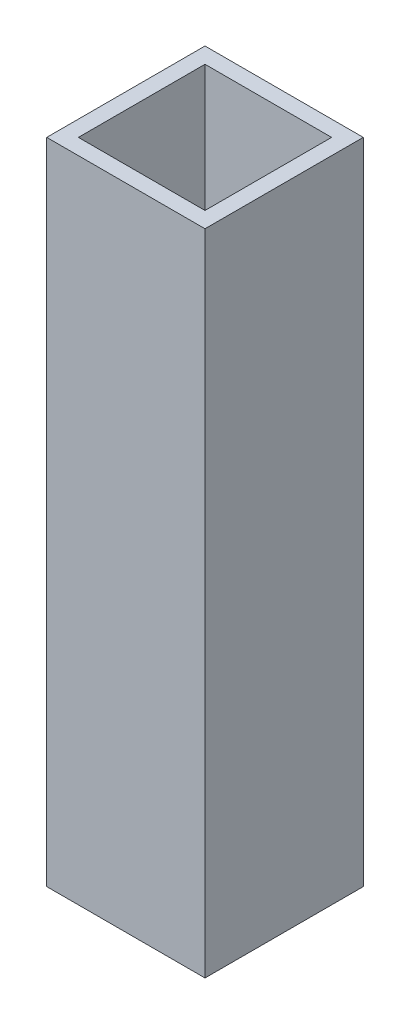
from build123d import *

# Parameters (mm, degrees)
SKETCH2_W           = 50
SKETCH2_H           = 50
SKETCH2_W_2         = 40
SKETCH2_H_2         = 40
BOSS_EXTRUDE1_DEPTH = 205


with BuildPart() as part:
    # Sketch2 → Boss-Extrude1 (new body)
    with BuildSketch(Plane(origin=(0, 0, 0), x_dir=(1, 0, 0), z_dir=(0, 1, 0))):
        Rectangle(SKETCH2_W, SKETCH2_H)
        Rectangle(SKETCH2_W_2, SKETCH2_H_2, mode=Mode.SUBTRACT)
    extrude(amount=BOSS_EXTRUDE1_DEPTH)


solid = part.part
